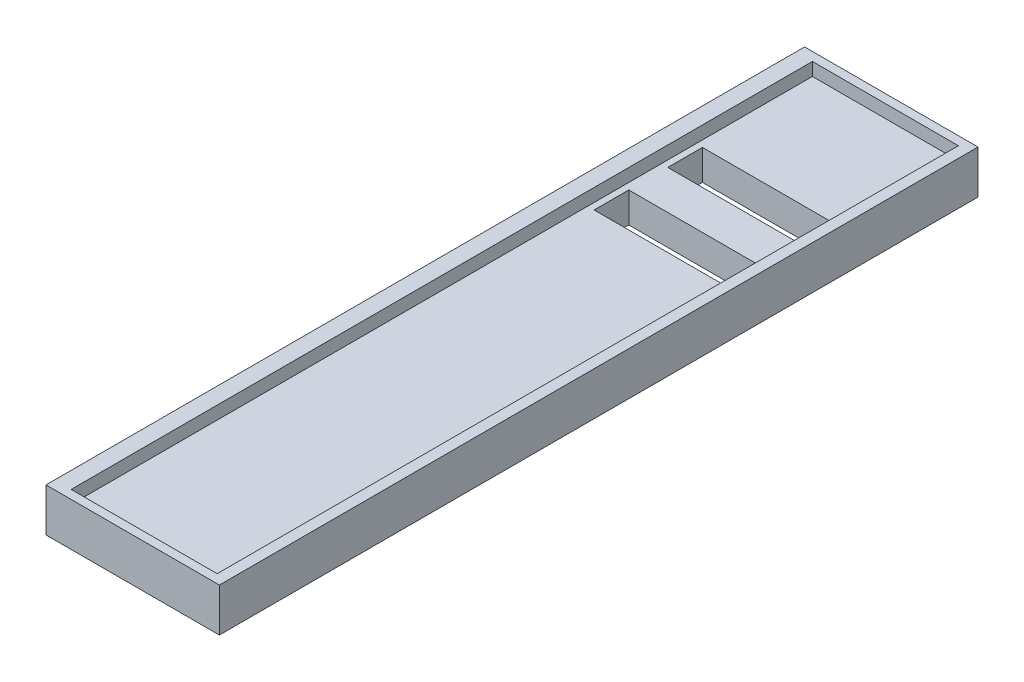
from build123d import *

# Parameters (mm, degrees)
SKETCH_1_W          = 80
SKETCH_1_H          = 20
EXTRUDE_1_DEPTH     = 350
SKETCH_2_W          = 67.355648201
SKETCH_2_H          = 6
CUT_EXTRUDE_1_DEPTH = 351
SKETCH_3_W          = 60.301963697
SKETCH_3_H          = 16
CUT_EXTRUDE_2_DEPTH = 15
SKETCH_4_W          = 67.355648201
SKETCH_4_H          = 6
EXTRUDE_2_DEPTH     = 4
SKETCH_5_W          = 67.355648201
SKETCH_5_H          = 6
EXTRUDE_3_DEPTH     = 4


with BuildPart() as part:
    # 草图1 → 凸台-拉伸1 (new body)
    with BuildSketch(Plane.XY):
        with Locations((-5.831622177, -5.58518109)):
            Rectangle(SKETCH_1_W, SKETCH_1_H)
    extrude(amount=EXTRUDE_1_DEPTH)

    # 草图2 → 切除-拉伸1 (cut, through all)
    with BuildSketch(Plane.XY.offset(350)):
        with Locations((-4.554011248, 1.41481891)):
            Rectangle(SKETCH_2_W, SKETCH_2_H)
    extrude(amount=-CUT_EXTRUDE_1_DEPTH, mode=Mode.SUBTRACT)

    # 草图3 → 切除-拉伸2 (cut, through all)
    with BuildSketch(Plane(origin=(0, -1.58518109, 0), x_dir=(1, 0, 0), z_dir=(0, 1, 0))):
        with Locations((-5.099475916, -65.71132948)):
            Rectangle(SKETCH_3_W, SKETCH_3_H)
        with Locations((-5.099475916, -99.71132948)):
            Rectangle(SKETCH_3_W, SKETCH_3_H)
    extrude(amount=-CUT_EXTRUDE_2_DEPTH, mode=Mode.SUBTRACT)

    # 草图4 → 凸台-拉伸2 (add)
    with BuildSketch(Plane.XY.offset(350)):
        with Locations((-4.554011248, 1.41481891)):
            Rectangle(SKETCH_4_W, SKETCH_4_H)
    extrude(amount=-EXTRUDE_2_DEPTH)

    # 草图5 → 凸台-拉伸3 (add)
    with BuildSketch(Plane(origin=(0, 0, 0), x_dir=(-1, 0, 0), z_dir=(0, 0, -1))):
        with Locations((4.554011248, 1.41481891)):
            Rectangle(SKETCH_5_W, SKETCH_5_H)
    extrude(amount=-EXTRUDE_3_DEPTH)


solid = part.part
